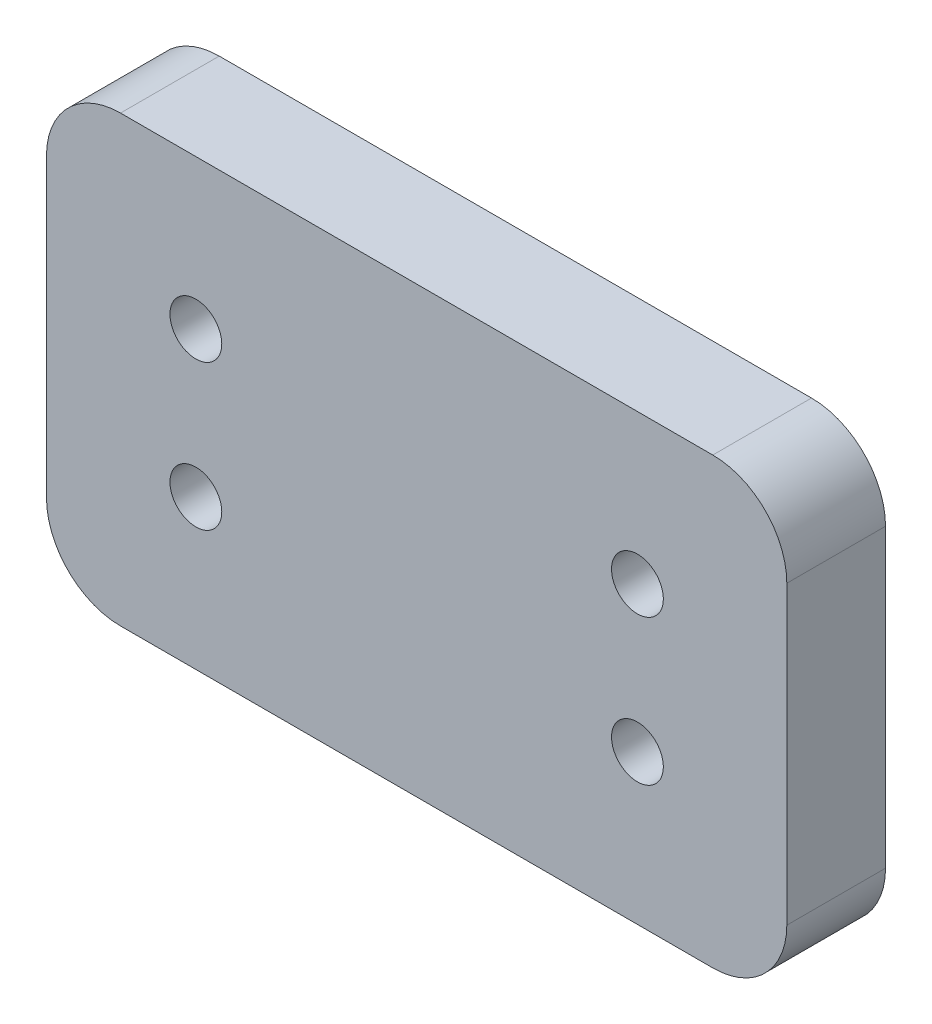
from build123d import *

# Parameters (mm, degrees)
ESQUISSE1_W             = 30
ESQUISSE1_H             = 18
BOSS_EXTRU_1_DEPTH      = 4
CONG_1_R                = 3
ESQUISSE2_R             = 1.05
ENL_V_MAT_EXTRU_1_DEPTH = 5


with BuildPart() as part:
    # Esquisse1 → Boss.-Extru.1 (new body)
    with BuildSketch(Plane.XY):
        with Locations((15, 9)):
            Rectangle(ESQUISSE1_W, ESQUISSE1_H)
    extrude(amount=BOSS_EXTRU_1_DEPTH)

    # Congé1
    cong_1_edges = [part.edges().sort_by_distance(p)[0] for p in [
        (0, 18, 2),
        (30, 18, 2),
        (30, 0, 2),
        (0, 0, 2),
    ]]
    fillet(cong_1_edges, radius=CONG_1_R)

    # Esquisse2 → Enlèv. mat.-Extru.1 (cut, through all)
    with BuildSketch(Plane.XY.offset(4)):
        with Locations((6.053, 11.947)):
            Circle(ESQUISSE2_R)
        with Locations((6.053, 6.053)):
            Circle(ESQUISSE2_R)
        with Locations((23.947, 11.947)):
            Circle(ESQUISSE2_R)
        with Locations((23.947, 6.053)):
            Circle(ESQUISSE2_R)
    extrude(amount=-ENL_V_MAT_EXTRU_1_DEPTH, mode=Mode.SUBTRACT)


solid = part.part
